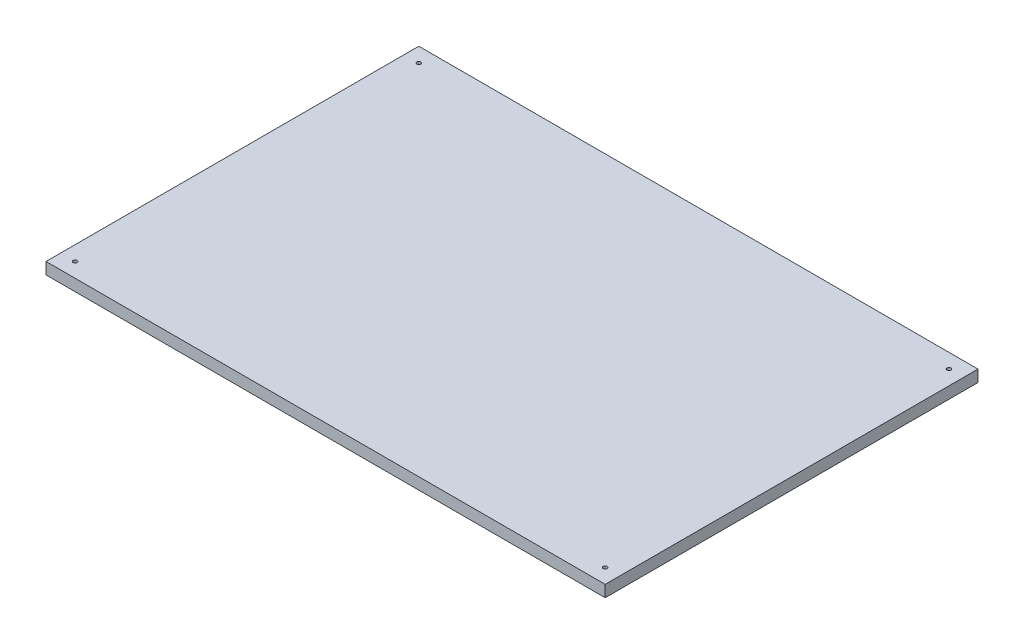
from build123d import *

# Parameters (mm, degrees)
SKETCH1_W           = 480
SKETCH1_H           = 320
BOSS_EXTRUDE1_DEPTH = 10
SKETCH2_R           = 1.7
CUT_EXTRUDE1_DEPTH  = 11


with BuildPart() as part:
    # Sketch1 → Boss-Extrude1 (new body)
    with BuildSketch(Plane(origin=(0, 0, 0), x_dir=(1, 0, 0), z_dir=(0, 1, 0))):
        with Locations((0.484565928, -82.206197664)):
            Rectangle(SKETCH1_W, SKETCH1_H)
    extrude(amount=BOSS_EXTRUDE1_DEPTH)

    # Sketch2 → Cut-Extrude1 (cut, through all)
    with BuildSketch(Plane(origin=(0, 10, 0), x_dir=(1, 0, 0), z_dir=(0, 1, 0))):
        with Locations((-227.015434072, 65.293802336)):
            Circle(SKETCH2_R)
        with Locations((227.984565928, -229.706197664)):
            Circle(SKETCH2_R)
        with Locations((227.984565928, 65.293802336)):
            Circle(SKETCH2_R)
        with Locations((-227.015434072, -229.706197664)):
            Circle(SKETCH2_R)
    extrude(amount=-CUT_EXTRUDE1_DEPTH, mode=Mode.SUBTRACT)


solid = part.part
